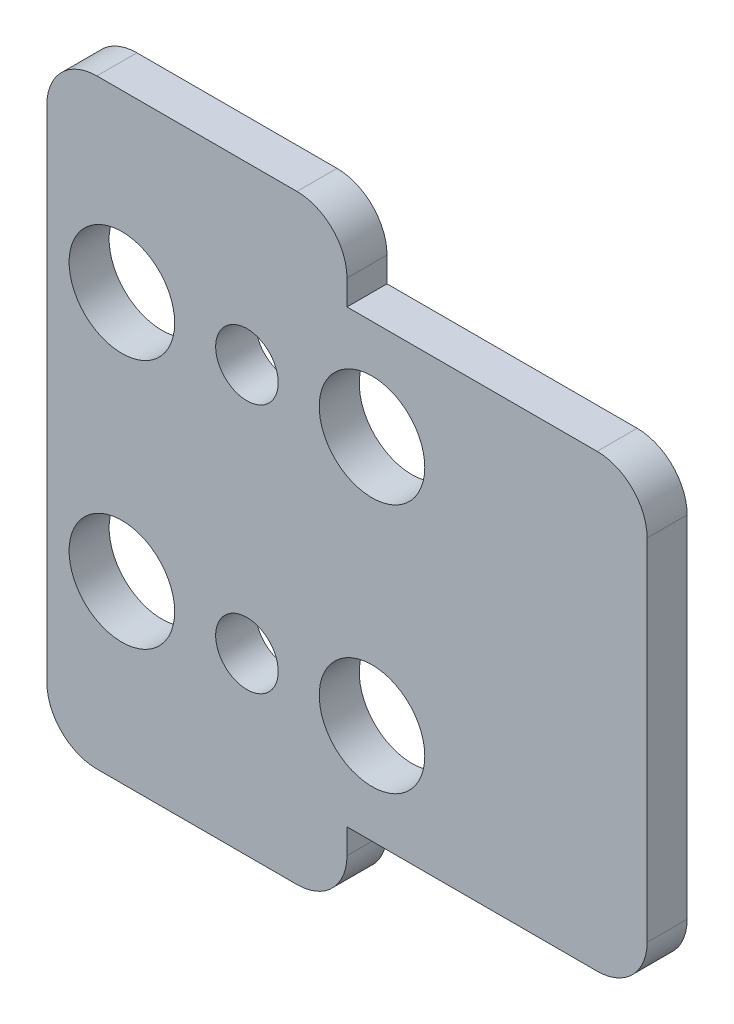
from build123d import *

# Parameters (mm, degrees)
SKETCH_1_R      = 2.11
SKETCH_1_R_2    = 1.25
EXTRUDE_1_DEPTH = 1.6
FILLET_1_R      = 2


with BuildPart() as part:
    # 草图1 → 凸台-拉伸1 (new body)
    with BuildSketch(Plane.XY):
        Polygon((12, 0), (0, 0), (0, -24), (12, -24), (12, -21), (24, -21), (24, -3), (12, -3), align=None)
        with Locations((13, -7)):
            Circle(SKETCH_1_R, mode=Mode.SUBTRACT)
        with Locations((13, -17)):
            Circle(SKETCH_1_R, mode=Mode.SUBTRACT)
        with Locations((3, -17)):
            Circle(SKETCH_1_R, mode=Mode.SUBTRACT)
        with Locations((8, -17)):
            Circle(SKETCH_1_R_2, mode=Mode.SUBTRACT)
        with Locations((3, -7)):
            Circle(SKETCH_1_R, mode=Mode.SUBTRACT)
        with Locations((8, -7)):
            Circle(SKETCH_1_R_2, mode=Mode.SUBTRACT)
    extrude(amount=EXTRUDE_1_DEPTH)

    # 圆角1
    fillet_1_edges = [part.edges().sort_by_distance(p)[0] for p in [
        (12, -24, 0.8),
        (0, -24, 0.8),
        (0, 0, 0.8),
        (12, 0, 0.8),
        (24, -3, 0.8),
        (24, -21, 0.8),
    ]]
    fillet(fillet_1_edges, radius=FILLET_1_R)


solid = part.part
